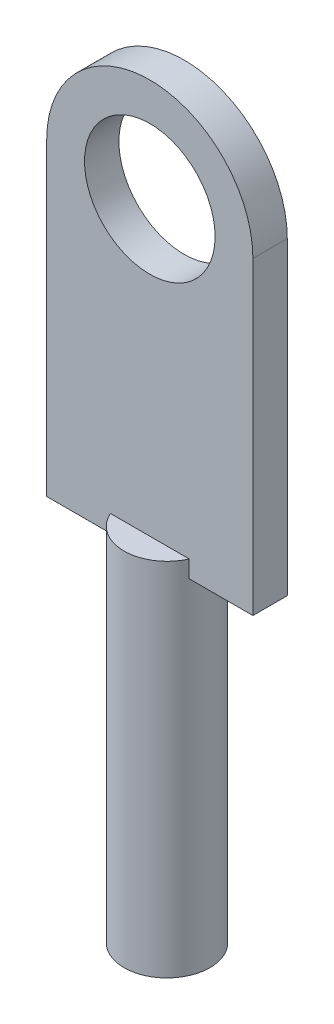
from build123d import *

# Parameters (mm, degrees)
SKETCH1_R      = 1.5875
EXTRUDE1_DEPTH = 8.255
SKETCH2_R      = 2.413
EXTRUDE2_DEPTH = 0.635
SKETCH3_R      = 1.5875
EXTRUDE3_DEPTH = 5.08


with BuildPart() as part:
    # Sketch1 → Extrude1 (new body)
    with BuildSketch(Plane(origin=(0, 0, 0), x_dir=(1, 0, 0), z_dir=(0, 1, 0))):
        Circle(SKETCH1_R)
    extrude(amount=EXTRUDE1_DEPTH)

    # Sketch2 → Extrude2 (add, symmetric)
    with BuildSketch(Plane.XY):
        with BuildLine():
            Line((-3.81, 19.05), (-3.81, 7.62))
            Line((-3.81, 7.62), (3.81, 7.62))
            Line((3.81, 7.62), (3.81, 19.05))
            ThreePointArc((3.81, 19.05), (0, 22.86), (-3.81, 19.05))
        make_face()
        with Locations((0, 19.05)):
            Circle(SKETCH2_R, mode=Mode.SUBTRACT)
    extrude(amount=EXTRUDE2_DEPTH, both=True)

    # Sketch3 → Extrude3 (add)
    with BuildSketch(Plane.XZ):
        Circle(SKETCH3_R)
    extrude(amount=EXTRUDE3_DEPTH)


solid = part.part
